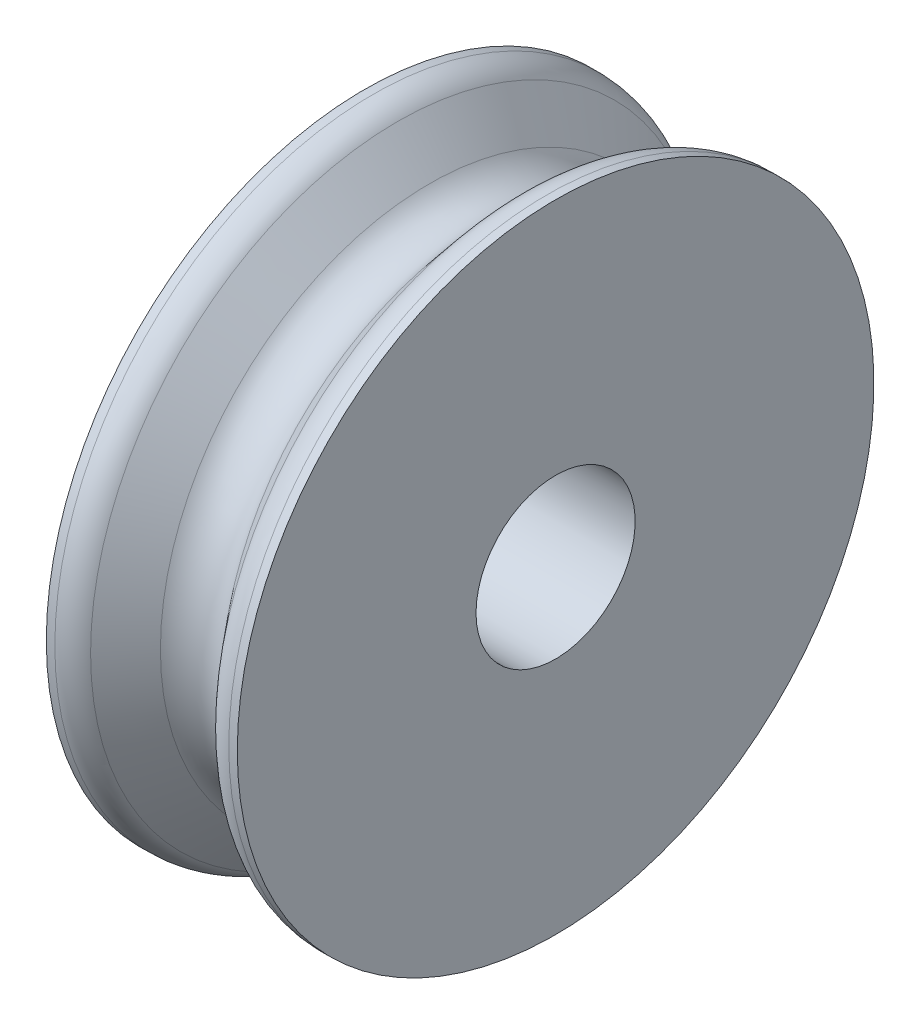
from build123d import *

# Parameters (mm, degrees)
FILLET1_R = 5


with BuildPart() as part:
    # Sketch1 → Revolve1 (revolve)
    with BuildSketch(Plane.XY):
        with BuildLine():
            Line((-11.328734558, 50), (-15, 50))
            Line((-15, 50), (-15, 12.5))
            Line((-15, 12.5), (0, 12.5))
            Line((0, 12.5), (0, 40))
            ThreePointArc((0, 40), (-2.662495049, 40.590260942), (-4.826079992, 42.250438059))
            Line((-4.826079992, 42.250438059), (-11.328734558, 50))
        make_face()
    revolve1 = revolve(axis=Axis((-75.888260409, 0, 0), (1, 0, 0)))

    # Mirror1: Revolve1 across plane
    add(revolve1.mirror(Plane(origin=(0, 12.5, 0), x_dir=(0, 0, 1), z_dir=(-1, 0, 0))))

    # Fillet1
    fillet1_edges = [part.edges().sort_by_distance(p)[0] for p in [
        (11.328734558, -50, 0),
        (-11.328734558, -50, 0),
    ]]
    fillet(fillet1_edges, radius=FILLET1_R)


solid = part.part
